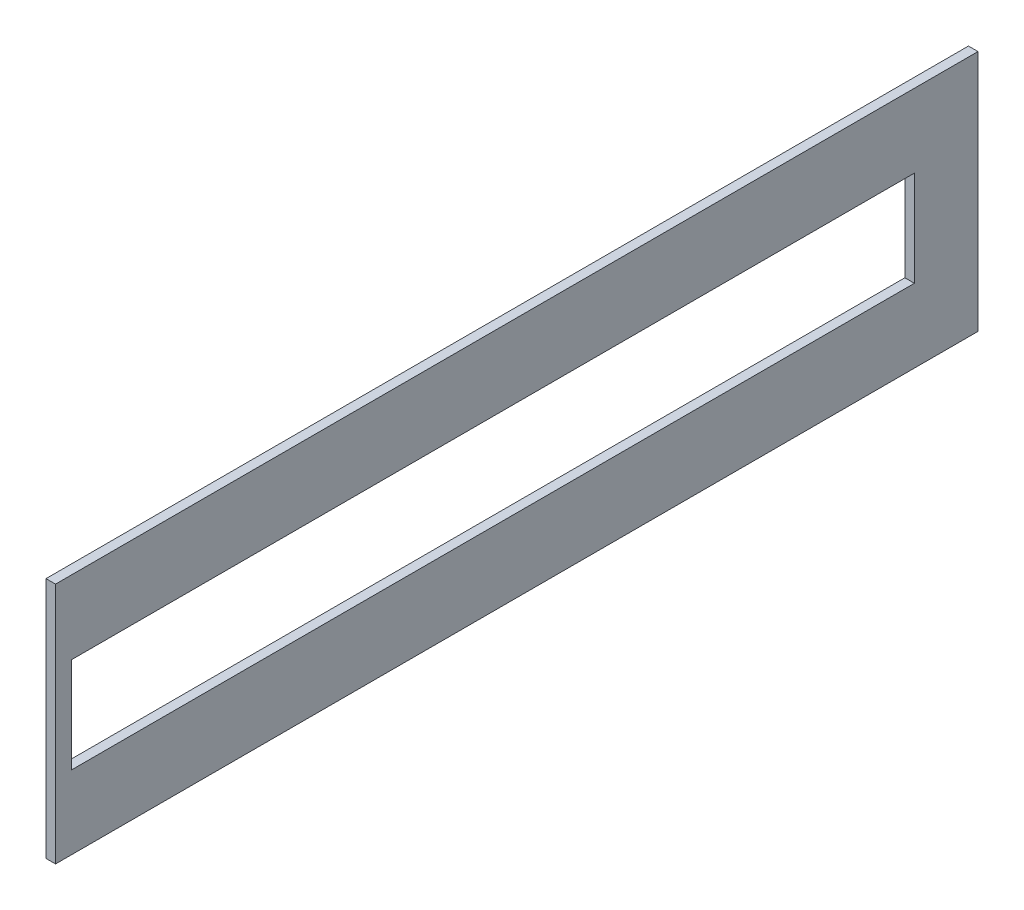
from build123d import *

# Parameters (mm, degrees)
SKETCH1_W           = 290
SKETCH1_H           = 76.2
BOSS_EXTRUDE1_DEPTH = 3
SKETCH3_W           = 265
SKETCH3_H           = 30
CUT_EXTRUDE1_DEPTH  = 4


with BuildPart() as part:
    # Sketch1 → Boss-Extrude1 (new body)
    with BuildSketch(Plane(origin=(0, 0, 0), x_dir=(0, 0, -1), z_dir=(1, 0, 0))):
        Rectangle(SKETCH1_W, SKETCH1_H)
    extrude(amount=BOSS_EXTRUDE1_DEPTH)

    # Sketch3 → Cut-Extrude1 (cut, through all)
    with BuildSketch(Plane(origin=(3, 0, 0), x_dir=(0, 0, -1), z_dir=(1, 0, 0))):
        with Locations((-7.5, 0)):
            Rectangle(SKETCH3_W, SKETCH3_H)
    extrude(amount=-CUT_EXTRUDE1_DEPTH, mode=Mode.SUBTRACT)


solid = part.part
